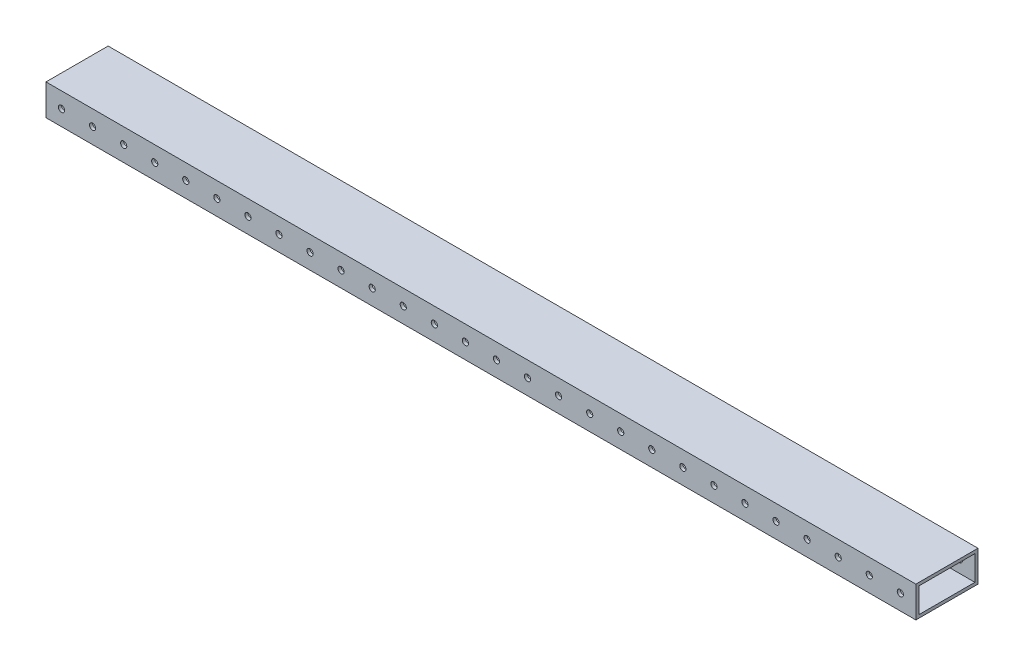
from build123d import *

# Parameters (mm, degrees)
SKETCH2_W           = 50.8
SKETCH2_H           = 25.4
SKETCH2_W_2         = 45.72
SKETCH2_H_2         = 20.32
BOSS_EXTRUDE1_DEPTH = 711.2
SKETCH3_R           = 2.54
CUT_EXTRUDE1_DEPTH  = 51.8
LPATTERN1_COUNT     = 28
LPATTERN1_PITCH     = 25.4


with BuildPart() as part:
    # Sketch2 → Boss-Extrude1 (new body)
    with BuildSketch(Plane(origin=(0, 0, 0), x_dir=(0, 0, -1), z_dir=(1, 0, 0))):
        with Locations((25.4, 12.7)):
            Rectangle(SKETCH2_W, SKETCH2_H)
        with Locations((25.4, 12.7)):
            Rectangle(SKETCH2_W_2, SKETCH2_H_2, mode=Mode.SUBTRACT)
    extrude(amount=BOSS_EXTRUDE1_DEPTH)

    # Sketch3 → Cut-Extrude1 (cut, through all)
    with BuildSketch(Plane.XY):
        with Locations((12.7, 12.7)):
            Circle(SKETCH3_R)
    cut_extrude1 = extrude(amount=-CUT_EXTRUDE1_DEPTH, mode=Mode.SUBTRACT)

    # LPattern1: Cut-Extrude1 ×28
    with Locations(*[(i * LPATTERN1_PITCH, 0, 0) for i in range(1, LPATTERN1_COUNT)]):
        add(cut_extrude1, mode=Mode.SUBTRACT)


solid = part.part
